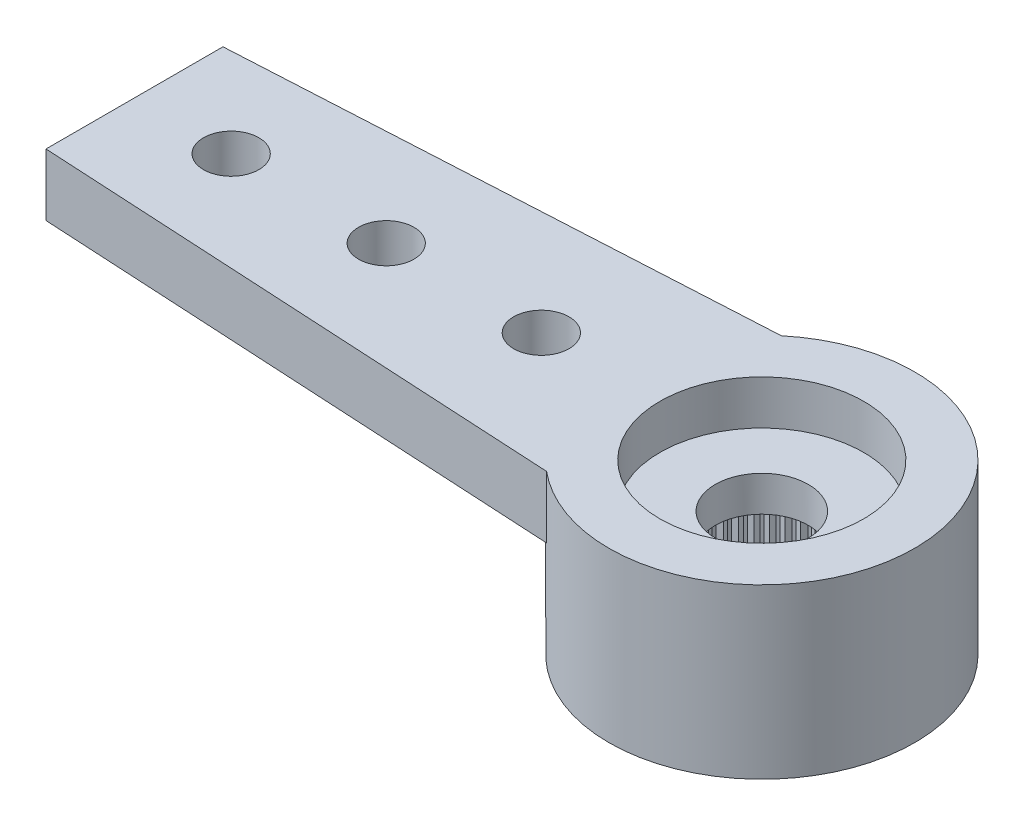
from build123d import *

# Parameters (mm, degrees)
RESSALTO_EXTRUS_O1_DEPTH = 1.4
ESBO_O2_R                = 3.45
RESSALTO_EXTRUS_O2_DEPTH = 2.4
FURO1_D                  = 4.95
FURO1_DEPTH              = 2
FURO2_D                  = 4.6
FURO2_DEPTH              = 1
FURO3_D                  = 2.1
RESSALTO_EXTRUS_O3_DEPTH = 2
PADR_OCIRCULAR1_COUNT    = 60
ESQUISSE1_R              = 0.625
ENL_V_MAT_EXTRU_1_DEPTH  = 4.8


with BuildPart() as part:
    # Esboço1 → Ressalto-extrusão1 (new body)
    with BuildSketch(Plane(origin=(0, 0, 0), x_dir=(1, 0, 0), z_dir=(0, 1, 0))):
        with BuildLine():
            Line((-14.159121967, 1.99702088), (-2.209072203, 2.65))
            ThreePointArc((-2.209072203, 2.65), (3.45, 0), (-2.209072203, -2.65))
            Line((-2.209072203, -2.65), (-14.159121967, -1.99702088))
            Line((-14.159121967, -1.99702088), (-14.159121967, 1.99702088))
        make_face()
    extrude(amount=-RESSALTO_EXTRUS_O1_DEPTH)

    # Esboço2 → Ressalto-extrusão2 (add)
    with BuildSketch(Plane.XZ.offset(1.4)):
        Circle(ESBO_O2_R)
    extrude(amount=RESSALTO_EXTRUS_O2_DEPTH)

    # Furo1
    with Locations(Plane(origin=(0, -3.8, 0), x_dir=(-1, 0, 0), z_dir=(0, -1, 0))):
        with Locations((0, 0)):
            Hole(FURO1_D / 2, depth=FURO1_DEPTH)

    # Furo2
    with Locations(Plane(origin=(0, 0, 0), x_dir=(1, 0, 0), z_dir=(0, 1, 0))):
        with Locations((0, 0)):
            Hole(FURO2_D / 2, depth=FURO2_DEPTH)

    # Furo3 (through all)
    with Locations(Plane(origin=(0, 0, 0), x_dir=(1, 0, 0), z_dir=(0, 1, 0))):
        with Locations((0, 0)):
            Hole(FURO3_D / 2)

    # Esboço11 → Ressalto-extrusão3 (add)
    with BuildSketch(Plane.XZ.offset(3.8)):
        with BuildLine():
            Line((-0.098056786, 2.473056786), (0, 2.375))
            Line((0, 2.375), (0.098056786, 2.473056786))
            ThreePointArc((0.098056786, 2.473056786), (0, 2.475), (-0.098056786, 2.473056786))
        make_face()
    ressalto_extrus_o3 = extrude(amount=-RESSALTO_EXTRUS_O3_DEPTH)

    # PadrãoCircular1: Ressalto-extrusão3 ×60 about axis
    padr_ocircular1_axis = Axis((0, 0, 0), (0, 1, 0))
    for i in range(1, PADR_OCIRCULAR1_COUNT):
        add(ressalto_extrus_o3.rotate(padr_ocircular1_axis, i * 360 / PADR_OCIRCULAR1_COUNT))

    # Esquisse1 → Enlèv. mat.-Extru.1 (cut, through all)
    with BuildSketch(Plane(origin=(0, 0, 0), x_dir=(1, 0, 0), z_dir=(0, 1, 0))):
        with Locations((-8.476862967, 0)):
            Circle(ESQUISSE1_R)
        with Locations((-4.976862967, 0)):
            Circle(ESQUISSE1_R)
        with Locations((-11.976862967, 0)):
            Circle(ESQUISSE1_R)
    extrude(amount=-ENL_V_MAT_EXTRU_1_DEPTH, mode=Mode.SUBTRACT)


solid = part.part
